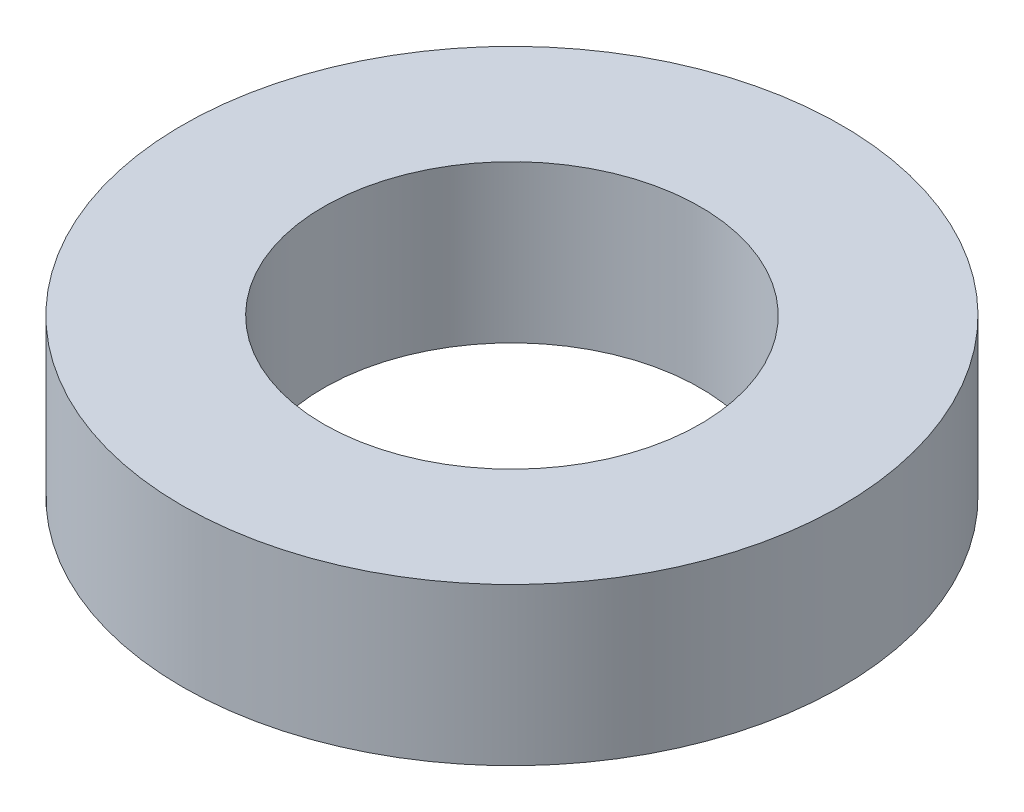
from build123d import *

# Parameters (mm, degrees)
SKETCH5_R           = 10.5
BOSS_EXTRUDE2_DEPTH = 5
SKETCH6_R           = 6
CUT_EXTRUDE3_DEPTH  = 8


with BuildPart() as part:
    # Sketch5 → Boss-Extrude2 (new body)
    with BuildSketch(Plane(origin=(0, 0, 0), x_dir=(1, 0, 0), z_dir=(0, 1, 0))):
        Circle(SKETCH5_R)
    extrude(amount=BOSS_EXTRUDE2_DEPTH)

    # Sketch6 → Cut-Extrude3 (cut)
    with BuildSketch(Plane(origin=(0, 5, 0), x_dir=(1, 0, 0), z_dir=(0, 1, 0))):
        Circle(SKETCH6_R)
    extrude(amount=-CUT_EXTRUDE3_DEPTH, mode=Mode.SUBTRACT)


solid = part.part
